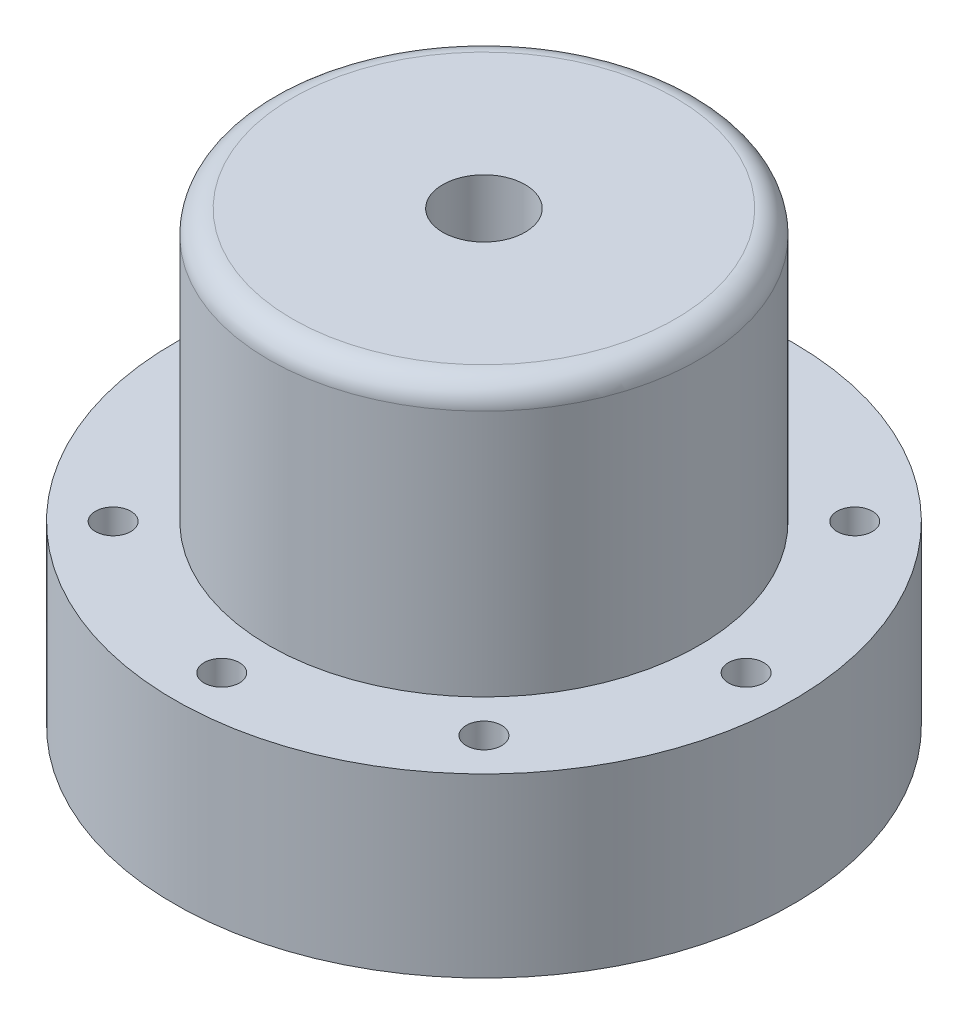
from build123d import *

# Parameters (mm, degrees)
SKETCH1_R           = 18.25
SKETCH1_R_2         = 13.25
BOSS_EXTRUDE1_DEPTH = 18
SKETCH2_R           = 26.25
SKETCH2_R_2         = 13.25
FLANGE_DEPTH        = 5
CUT_EXTRUDE1_REACH  = 43.257
SKETCH4_R           = 1.5
CIRPATTERN1_COUNT   = 8
SKETCH6_R           = 18.25
SKETCH6_R_2         = 3.5
TOP_DEPTH           = 5
SKETCH7_R           = 26.25
SKETCH7_R_2         = 19.25
SKETCH7_R_3         = 1.5
BOSS_EXTRUDE5_DEPTH = 10
FILLET1_R           = 2


with BuildPart() as part:
    # Sketch1 → Boss-Extrude1 (new body)
    with BuildSketch(Plane(origin=(0, 0, 0), x_dir=(1, 0, 0), z_dir=(0, 1, 0))):
        with Locations(Location((0, 0, 0), (0, 0, 270))):
            Circle(SKETCH1_R)
        with Locations(Location((0, 0, 0), (0, 0, 270))):
            Circle(SKETCH1_R_2, mode=Mode.SUBTRACT)
    extrude(amount=BOSS_EXTRUDE1_DEPTH)

    # Sketch2 → flange (add)
    with BuildSketch(Plane.XZ):
        with Locations(Location((0, 0, 0), (0, 0, 270))):
            Circle(SKETCH2_R)
        with Locations(Location((0, 0, 0), (0, 0, 270))):
            Circle(SKETCH2_R_2, mode=Mode.SUBTRACT)
    extrude(amount=FLANGE_DEPTH)

    # Sketch4 → Cut-Extrude1 (cut, up to next)
    with BuildSketch(Plane(origin=(0, 0, 0), x_dir=(1, 0, 0), z_dir=(0, 1, 0)), mode=Mode.PRIVATE) as cut_extrude1_sk1:
        with Locations(Location((0, -22.25, 0), (0, 0, 270))):
            Circle(SKETCH4_R)
    cut_extrude1_tool1 = extrude(cut_extrude1_sk1.sketch, amount=-CUT_EXTRUDE1_REACH, mode=Mode.PRIVATE) & part.part
    cut_extrude1 = cut_extrude1_tool1.solids().sort_by_distance((0, 0, 22.25))[0]
    add(cut_extrude1, mode=Mode.SUBTRACT)

    # CirPattern1: Cut-Extrude1 ×8 about axis
    cirpattern1_axis = Axis((0, 0, 0), (0, 1, 0))
    for i in range(1, CIRPATTERN1_COUNT):
        add(cut_extrude1.rotate(cirpattern1_axis, i * 360 / CIRPATTERN1_COUNT), mode=Mode.SUBTRACT)

    # Sketch6 → top (add)
    with BuildSketch(Plane(origin=(0, 18, 0), x_dir=(1, 0, 0), z_dir=(0, 1, 0))):
        with Locations(Location((0, 0, 0), (0, 0, 270))):
            Circle(SKETCH6_R)
        with Locations(Location((0, 0, 0), (0, 0, 270))):
            Circle(SKETCH6_R_2, mode=Mode.SUBTRACT)
    extrude(amount=TOP_DEPTH)

    # Sketch7 → Boss-Extrude5 (add)
    with BuildSketch(Plane.XZ.offset(5)):
        with Locations(Location((0, 0, 0), (0, 0, 270))):
            Circle(SKETCH7_R)
        with Locations(Location((0, 0, 0), (0, 0, 270))):
            Circle(SKETCH7_R_2, mode=Mode.SUBTRACT)
        with Locations(Location((-15.733125881, -15.733125881, 0), (0, 0, 225))):
            Circle(SKETCH7_R_3, mode=Mode.SUBTRACT)
        with Locations(Location((15.733125881, -15.733125881, 0), (0, 0, 315))):
            Circle(SKETCH7_R_3, mode=Mode.SUBTRACT)
        with Locations(Location((15.733125881, 15.733125881, 0), (0, 0, 45))):
            Circle(SKETCH7_R_3, mode=Mode.SUBTRACT)
        with Locations(Location((0, 22.25, 0), (0, 0, 90))):
            Circle(SKETCH7_R_3, mode=Mode.SUBTRACT)
        with Locations(Location((-15.733125881, 15.733125881, 0), (0, 0, 135))):
            Circle(SKETCH7_R_3, mode=Mode.SUBTRACT)
        with Locations((22.25, 0)):
            Circle(SKETCH7_R_3, mode=Mode.SUBTRACT)
        with Locations(Location((0, -22.25, 0), (0, 0, 270))):
            Circle(SKETCH7_R_3, mode=Mode.SUBTRACT)
        with Locations(Location((-22.25, 0, 0), (0, 0, 180))):
            Circle(SKETCH7_R_3, mode=Mode.SUBTRACT)
    extrude(amount=BOSS_EXTRUDE5_DEPTH)

    # Fillet1
    fillet1_edges = [part.edges().sort_by_distance(p)[0] for p in [
        (0, 23, -18.25),
    ]]
    fillet(fillet1_edges, radius=FILLET1_R)


solid = part.part
